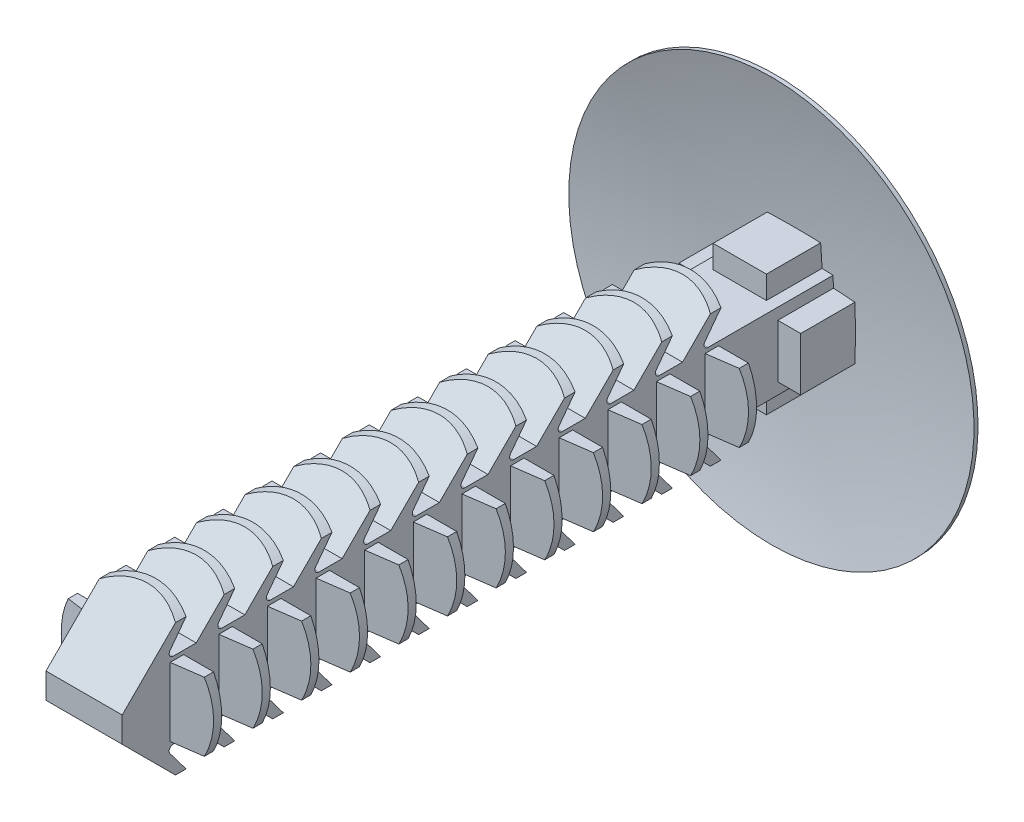
from build123d import *

# Parameters (mm, degrees)
SKETCH3_W                       = 2.3876
SKETCH3_H                       = 2.3876
BOSS_EXTRUDE1_DEPTH             = 11.7602
BOSS_EXTRUDE1_DIRECTION_2_REACH = 13.76
CHAMFER1_SIZE                   = 0.795866667
BOSS_EXTRUDE2_DEPTH             = 1.1938
BOSS_EXTRUDE3_DEPTH             = 1.07442
SKETCH6_OUTSIDE_W               = 20.618
SKETCH6_OUTSIDE_H               = 20.618
SKETCH6_OUTSIDE_R               = 2.3876
CUT_EXTRUDE3_DEPTH              = 12.7602
FILLET1_R                       = 0.127
LPATTERN2_COUNT                 = 12
LPATTERN2_PITCH                 = 1.524
LPATTERN2_2_COUNT               = 12
LPATTERN2_2_PITCH               = 1.524
FILLET1_OF_LPATTERN2_R          = 0.127
LPATTERN3_COUNT                 = 12
LPATTERN3_PITCH                 = 1.524
LPATTERN3_2_COUNT               = 12
LPATTERN3_2_PITCH               = 1.524
SKETCH8_W                       = 1.67132
SKETCH8_H                       = 3.82016
BOSS_EXTRUDE4_DEPTH             = 0.9906
CIRPATTERN1_COUNT               = 2
CIRPATTERN1_ANGLE               = 90


with BuildPart() as part:
    # Sketch2 → Revolve1 (revolve)
    with BuildSketch(Plane(origin=(0, 0, 0), x_dir=(0, 0, -1), z_dir=(1, 0, 0))):
        with BuildLine():
            Line((9.906, 6.35), (9.779, 6.35))
            ThreePointArc((9.779, 6.35), (10.372594518, 3.199629844), (10.57148, 0))
            Line((10.57148, 0), (11.7602, 0))
            ThreePointArc((11.7602, 0), (11.287169028, 3.307588156), (9.906, 6.35))
        make_face()
    revolve(axis=Axis((0, 0, 11.7602), (0, 0, -1)))


with BuildPart() as body_2:
    # Sketch3 → Boss-Extrude1 (new body)
    with BuildSketch(Plane.XY):
        Rectangle(SKETCH3_W, SKETCH3_H)
    extrude(amount=BOSS_EXTRUDE1_DEPTH)


    # Sketch3 → Boss-Extrude1 direction 2 (add, up to next)
    with BuildSketch(Plane.XY, mode=Mode.PRIVATE) as boss_extrude1_direction_2_sk1:
        Rectangle(SKETCH3_W, SKETCH3_H)
    boss_extrude1_direction_2_tool1 = extrude(boss_extrude1_direction_2_sk1.sketch, amount=-BOSS_EXTRUDE1_DIRECTION_2_REACH, mode=Mode.PRIVATE) - part.part
    add(boss_extrude1_direction_2_tool1.solids().sort_by_distance((0, 0, 0))[0])

    # Chamfer1
    chamfer1_edges = [body_2.edges().sort_by_distance(p)[0] for p in [
        (0, 1.1938, 11.7602),
        (0, -1.1938, 11.7602),
    ]]
    chamfer(chamfer1_edges, length=CHAMFER1_SIZE)

    # Sketch4 → Boss-Extrude2 (add, symmetric)
    with BuildSketch(Plane(origin=(0, 0, 0), x_dir=(0, 0, -1), z_dir=(1, 0, 0))):
        Polygon((-10.964333333, 1.1938), (-9.770533333, 2.3876), (-9.516533333, 2.3876), (-10.416126158, 1.1938), align=None)
        Polygon((-9.770533333, -2.3876), (-9.516533333, -2.3876), (-10.416126158, -1.1938), (-10.964333333, -1.1938), align=None)
    boss_extrude2 = extrude(amount=BOSS_EXTRUDE2_DEPTH, both=True)

    # Sketch5 → Boss-Extrude3 (add, symmetric)
    with BuildSketch(Plane(origin=(0, 0, 0), x_dir=(1, 0, 0), z_dir=(0, 1, 0))):
        Polygon((2.3876, -10.08888), (2.3876, -9.83488), (1.1938, -9.83488), (1.1938, -10.256657648), align=None)
        Polygon((-2.3876, -9.83488), (-1.1938, -9.83488), (-1.1938, -10.256657648), (-2.3876, -10.08888), align=None)
    boss_extrude3 = extrude(amount=BOSS_EXTRUDE3_DEPTH, both=True)

    # Sketch6 outside → Cut-Extrude3 (cut, through all)
    with BuildSketch(Plane.XY):
        Rectangle(SKETCH6_OUTSIDE_W, SKETCH6_OUTSIDE_H)
        Circle(SKETCH6_OUTSIDE_R, mode=Mode.SUBTRACT)
    cut_extrude3 = extrude(amount=CUT_EXTRUDE3_DEPTH, mode=Mode.SUBTRACT)

    # Fillet1
    fillet1_edges = [body_2.edges().sort_by_distance(p)[0] for p in [
        (0, 1.1938, 10.416126158),
        (0, -1.1938, 10.416126158),
    ]]
    fillet(fillet1_edges, radius=FILLET1_R)

    # LPattern2: Boss-Extrude2 ×12
    with Locations(*[(0, 0, -i * LPATTERN2_PITCH) for i in range(1, LPATTERN2_COUNT)]):
        add(boss_extrude2)

    # LPattern2 2: Cut-Extrude3 ×12
    with Locations(*[(0, 0, -i * LPATTERN2_2_PITCH) for i in range(1, LPATTERN2_2_COUNT)]):
        add(cut_extrude3, mode=Mode.SUBTRACT)

    # Fillet1 of LPattern2
    fillet1_of_lpattern2_edges = [body_2.edges().sort_by_distance(p)[0] for p in [
        (0, 1.1938, 8.892126158),
        (0, -1.1938, 8.892126158),
        (0, 1.1938, 7.368126158),
        (0, -1.1938, 7.368126158),
        (0, 1.1938, 5.844126158),
        (0, -1.1938, 5.844126158),
        (0, 1.1938, 4.320126158),
        (0, -1.1938, 4.320126158),
        (0, 1.1938, 2.796126158),
        (0, -1.1938, 2.796126158),
        (0, 1.1938, 1.272126158),
        (0, -1.1938, 1.272126158),
        (0, 1.1938, -0.251873842),
        (0, -1.1938, -0.251873842),
        (0, 1.1938, -1.775873842),
        (0, -1.1938, -1.775873842),
        (0, 1.1938, -3.299873842),
        (0, -1.1938, -3.299873842),
        (0, 1.1938, -4.823873842),
        (0, -1.1938, -4.823873842),
        (0, 1.1938, -6.347873842),
        (0, -1.1938, -6.347873842),
    ]]
    fillet(fillet1_of_lpattern2_edges, radius=FILLET1_OF_LPATTERN2_R)

    # LPattern3: Boss-Extrude3 ×12
    with Locations(*[(0, 0, -i * LPATTERN3_PITCH) for i in range(1, LPATTERN3_COUNT)]):
        add(boss_extrude3)

    # LPattern3 2: Cut-Extrude3 ×12
    with Locations(*[(0, 0, -i * LPATTERN3_2_PITCH) for i in range(1, LPATTERN3_2_COUNT)]):
        add(cut_extrude3, mode=Mode.SUBTRACT)

    # Combine1: union part
    add(part.part)

    # Sketch8 → Boss-Extrude4 (add, symmetric)
    with BuildSketch(Plane.XY.offset(-9.779)):
        Rectangle(SKETCH8_W, SKETCH8_H)
    boss_extrude4 = extrude(amount=BOSS_EXTRUDE4_DEPTH, both=True)

    # CirPattern1: Boss-Extrude4 ×2 about axis
    cirpattern1_axis = Axis((0, 0, 0), (0, 0, -1))
    for i in range(1, CIRPATTERN1_COUNT):
        add(boss_extrude4.rotate(cirpattern1_axis, i * CIRPATTERN1_ANGLE / (CIRPATTERN1_COUNT - 1)))


solid = body_2.part
